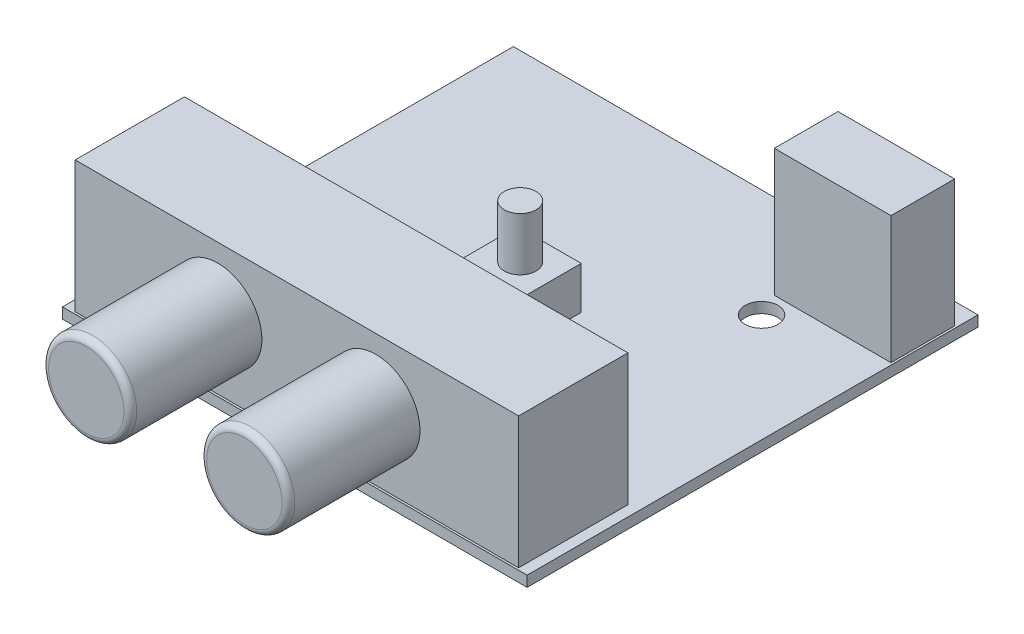
from build123d import *

# Parameters (mm, degrees)
SKETCH1_W           = 43.8
SKETCH1_H           = 42.5
BOSS_EXTRUDE1_DEPTH = 1
SKETCH2_W           = 41.8
SKETCH2_H           = 10.3
BOSS_EXTRUDE2_DEPTH = 12.4
SKETCH3_R           = 4.15
BOSS_EXTRUDE3_DEPTH = 12.4
SKETCH4_W           = 11
SKETCH4_H           = 6
BOSS_EXTRUDE4_DEPTH = 12
SKETCH5_W           = 6
SKETCH5_H           = 6
BOSS_EXTRUDE5_DEPTH = 4
SKETCH6_R           = 1.5
BOSS_EXTRUDE6_DEPTH = 5
SKETCH7_R           = 1.55
CUT_EXTRUDE1_DEPTH  = 2
FILLET1_R           = 0.6


with BuildPart() as part:
    # Sketch1 → Boss-Extrude1 (new body)
    with BuildSketch(Plane(origin=(0, 0, 0), x_dir=(1, 0, 0), z_dir=(0, 1, 0))):
        Rectangle(SKETCH1_W, SKETCH1_H)
    extrude(amount=BOSS_EXTRUDE1_DEPTH)

    # Sketch2 → Boss-Extrude2 (add)
    with BuildSketch(Plane(origin=(0, 1, 0), x_dir=(1, 0, 0), z_dir=(0, 1, 0))):
        with Locations((0, -15.9)):
            Rectangle(SKETCH2_W, SKETCH2_H)
    extrude(amount=BOSS_EXTRUDE2_DEPTH)

    # Sketch3 → Boss-Extrude3 (add)
    with BuildSketch(Plane.XY.offset(21.05)):
        with Locations((7.45, 7.55)):
            Circle(SKETCH3_R)
        with Locations((-7.45, 7.55)):
            Circle(SKETCH3_R)
    extrude(amount=BOSS_EXTRUDE3_DEPTH)

    # Sketch4 → Boss-Extrude4 (add)
    with BuildSketch(Plane(origin=(0, 1, 0), x_dir=(1, 0, 0), z_dir=(0, 1, 0))):
        with Locations((16.2, 16.25)):
            Rectangle(SKETCH4_W, SKETCH4_H)
    extrude(amount=BOSS_EXTRUDE4_DEPTH)

    # Sketch5 → Boss-Extrude5 (add)
    with BuildSketch(Plane(origin=(0, 1, 0), x_dir=(1, 0, 0), z_dir=(0, 1, 0))):
        with Locations((0, -0.25)):
            Rectangle(SKETCH5_W, SKETCH5_H)
    extrude(amount=BOSS_EXTRUDE5_DEPTH)

    # Sketch6 → Boss-Extrude6 (add)
    with BuildSketch(Plane(origin=(0, 5, 0), x_dir=(1, 0, 0), z_dir=(0, 1, 0))):
        Circle(SKETCH6_R)
    extrude(amount=BOSS_EXTRUDE6_DEPTH)

    # Sketch7 → Cut-Extrude1 (cut, through all)
    with BuildSketch(Plane(origin=(0, 1, 0), x_dir=(1, 0, 0), z_dir=(0, 1, 0))):
        with Locations((11.7, 11.05)):
            Circle(SKETCH7_R)
    extrude(amount=-CUT_EXTRUDE1_DEPTH, mode=Mode.SUBTRACT)

    # Fillet1
    fillet1_edges = [part.edges().sort_by_distance(p)[0] for p in [
        (3.3, 7.55, 33.45),
        (-11.6, 7.55, 33.45),
    ]]
    fillet(fillet1_edges, radius=FILLET1_R)


solid = part.part
